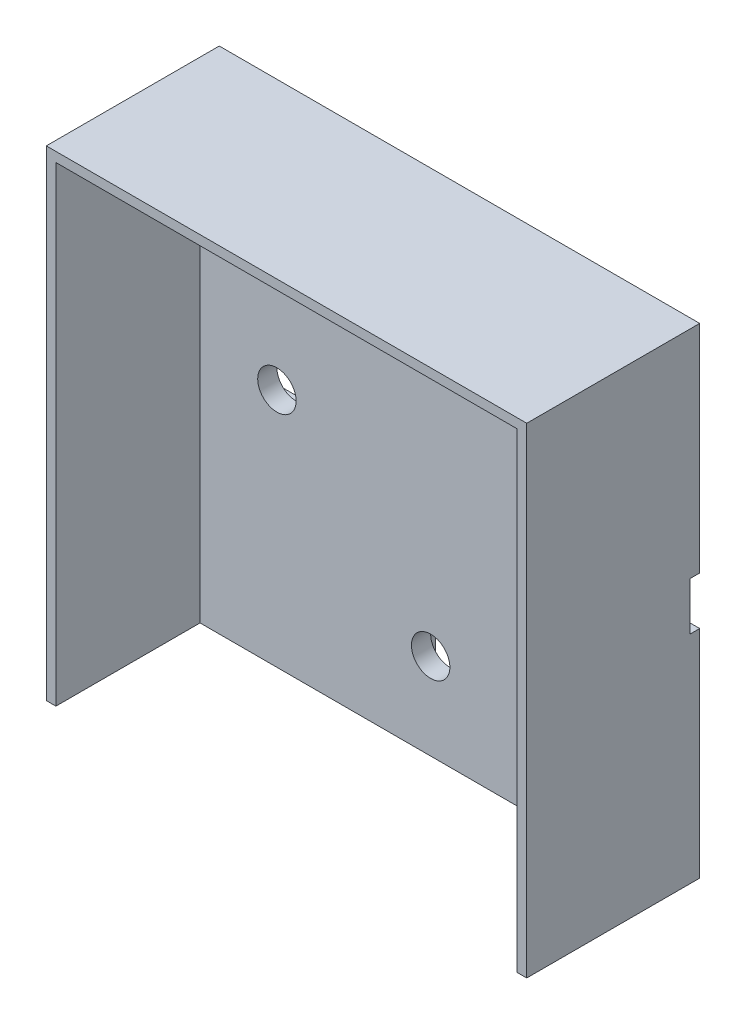
from build123d import *

# Parameters (mm, degrees)
SKICA1_W                 = 50
SKICA1_H                 = 50
P_IDAT_VYSUNUT_M2_DEPTH  = 3
SKICA5_W                 = 5
SKICA5_H                 = 22.5
SKICA5_W_2               = 50
SKICA5_H_2               = 5
ODEBRAT_VYSUNUT_M3_DEPTH = 1
P_IDAT_VYSUNUT_M9_DEPTH  = 15
SKICA17_R                = 2
ODEBRAT_VYSUNUT_M8_DEPTH = 4


with BuildPart() as part:
    # Skica1 → Přidat vysunutím2 (new body)
    with BuildSketch(Plane.XY):
        Rectangle(SKICA1_W, SKICA1_H)
    extrude(amount=P_IDAT_VYSUNUT_M2_DEPTH)

    # Skica5 → Odebrat vysunutím3 (cut)
    with BuildSketch(Plane(origin=(0, 0, 0), x_dir=(-1, 0, 0), z_dir=(0, 0, -1))):
        with Locations((0, -13.75)):
            Rectangle(SKICA5_W, SKICA5_H)
        Rectangle(SKICA5_W_2, SKICA5_H_2)
    extrude(amount=-ODEBRAT_VYSUNUT_M3_DEPTH, mode=Mode.SUBTRACT)

    # Skica14 → Přidat vysunutím9 (add)
    with BuildSketch(Plane.XY.offset(3)):
        Polygon((25, 25), (-25, 25), (-25, -25), (-24, -25), (-24, 24), (24, 24), (24, -25), (25, -25), align=None)
    extrude(amount=P_IDAT_VYSUNUT_M9_DEPTH)

    # Skica17 → Odebrat vysunutím8 (cut)
    with BuildSketch(Plane(origin=(0, 0, 1), x_dir=(-1, 0, 0), z_dir=(0, 0, -1))):
        with Locations((-16, 0)):
            Circle(SKICA17_R)
        with Locations((16, 0)):
            Circle(SKICA17_R)
        with Locations((0, -16)):
            Circle(SKICA17_R)
    extrude(amount=-ODEBRAT_VYSUNUT_M8_DEPTH, mode=Mode.SUBTRACT)


solid = part.part
